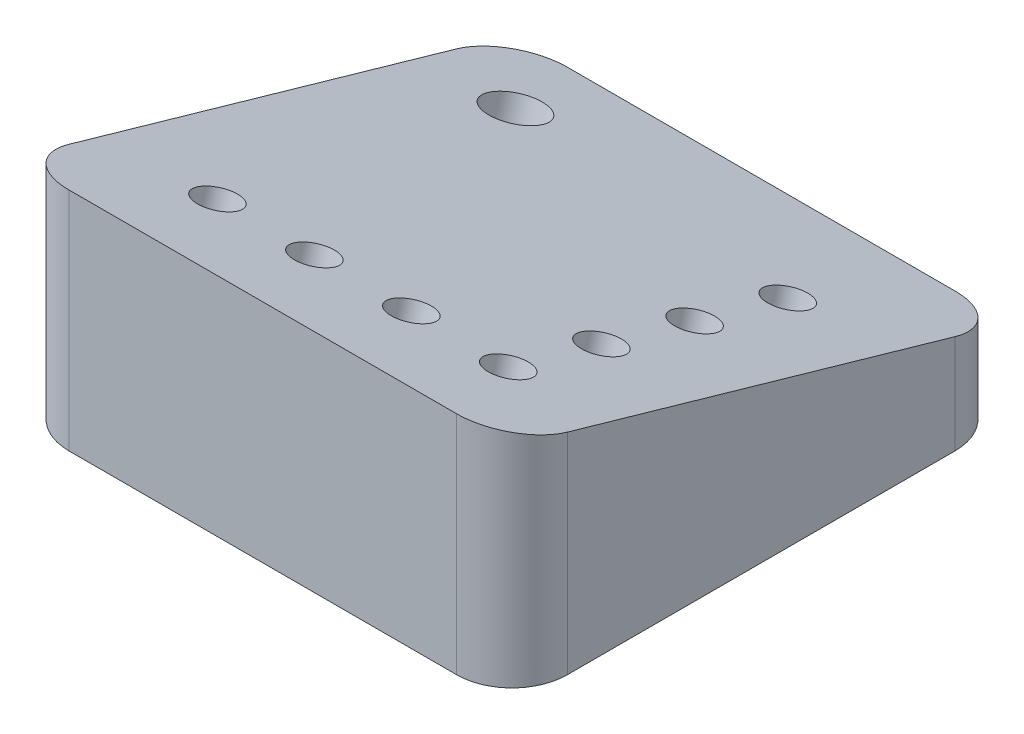
from build123d import *

# Parameters (mm, degrees)
BOSS_EXTRUDE1_DEPTH = 36
FILLET2_R           = 8
SKETCH4_R           = 4
CUT_EXTRUDE2_DEPTH  = 32.38102997
SKETCH3_R           = 3
CUT_EXTRUDE3_DEPTH  = 12


with BuildPart() as part:
    # Sketch2 → Boss-Extrude1 (new body, symmetric)
    with BuildSketch(Plane(origin=(0, 0, 0), x_dir=(0, 0, -1), z_dir=(1, 0, 0))):
        Polygon((37.235479123, 0), (37.235479123, 12), (-34.764520877, 32.645667775), (-34.764520877, 0), align=None)
    extrude(amount=BOSS_EXTRUDE1_DEPTH, both=True)

    # Fillet2
    fillet2_edges = [part.edges().sort_by_distance(p)[0] for p in [
        (36, 6, -37.235479123),
        (-36, 6, -37.235479123),
        (-36, 16.322833887, 34.764520877),
        (36, 16.322833887, 34.764520877),
    ]]
    fillet(fillet2_edges, radius=FILLET2_R)

    # Sketch4 → Cut-Extrude2 (cut, through all)
    with BuildSketch(Plane(origin=(0, 20.954187427, -6.008516557), x_dir=(1, 0, 0), z_dir=(0, 0.961261696, -0.275637356))):
        with Locations((-23, 19.485391541)):
            Circle(SKETCH4_R)
    extrude(amount=-CUT_EXTRUDE2_DEPTH, mode=Mode.SUBTRACT)

    # Sketch3 → Cut-Extrude3 (cut)
    with BuildSketch(Plane(origin=(0, 20.954187427, -6.008516557), x_dir=(1, 0, 0), z_dir=(0, 0.961261696, -0.275637356))):
        with Locations((-20, -28.416167841)):
            Circle(SKETCH3_R)
        with Locations((-6, -28.416167841)):
            Circle(SKETCH3_R)
        with Locations((8, -28.416167841)):
            Circle(SKETCH3_R)
        with Locations((22, -28.416167841)):
            Circle(SKETCH3_R)
        with Locations((22, -14.416167841)):
            Circle(SKETCH3_R)
        with Locations((22, -0.416167841)):
            Circle(SKETCH3_R)
        with Locations((22, 13.583832159)):
            Circle(SKETCH3_R)
    extrude(amount=-CUT_EXTRUDE3_DEPTH, mode=Mode.SUBTRACT)


solid = part.part
